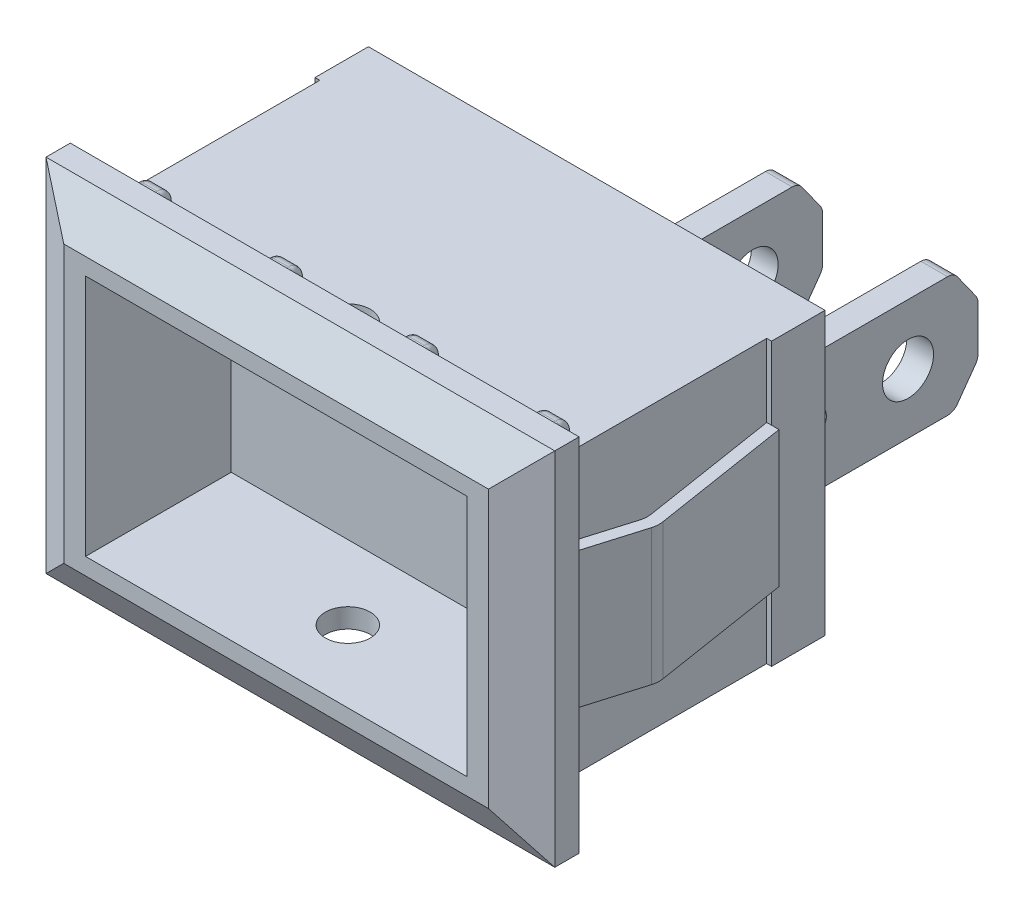
from build123d import *

# Parameters (mm, degrees)
IZIM1_W                           = 18.8
IZIM1_H                           = 11.6
Y_KSEKLIK_EKSTR_ZYON1_DEPTH       = 2.2
IZIM2_W                           = 18.4
IZIM2_H                           = 11.6
Y_KSEKLIK_EKSTR_ZYON2_DEPTH       = 9
IZIM3_W                           = 0.95
IZIM3_H                           = 3.7
Y_KSEKLIK_EKSTR_ZYON3_DEPTH       = 1
IZIM4_W                           = 0.95
IZIM4_H                           = 3.7
Y_KSEKLIK_EKSTR_ZYON4_DEPTH       = 1
IZIM5_W                           = 1.1
IZIM5_H                           = 4.95
Y_KSEKLIK_EKSTR_ZYON5_DEPTH       = 8.25
IZIM6_R                           = 1.05
KES_EKSTR_ZYON1_DEPTH             = 8.25
RADYUS1_R                         = 0.5
IZIM7_W                           = 20.95
IZIM7_H                           = 14.85
Y_KSEKLIK_EKSTR_ZYON6_DEPTH       = 2
KES_EKSTR_ZYON2_DEPTH             = 19
KES_EKSTR_ZYON3_DEPTH             = 23
IZIM10_W                          = 15.7
IZIM10_H                          = 10
KES_EKSTR_ZYON5_DEPTH             = 6
IZIM11_W                          = 1
IZIM11_H                          = 1.5
Y_KSEKLIK_EKSTR_ZYON7_DEPTH       = 0.7
RADYUS2_R                         = 0.5
RADYUS3_R                         = 0.2
IZIM13_W                          = 1
IZIM13_H                          = 1.5
Y_KSEKLIK_EKSTR_ZYON8_DEPTH       = 0.7
RADYUS4_R                         = 0.5
RADYUS5_R                         = 0.2
Y_KSEKLIK_EKSTR_ZYON9_DEPTH       = 2.8
Y_KSEKLIK_EKSTR_ZYON9_DEPTH_BACK  = 2.8
RADYUS6_R                         = 1
Y_KSEKLIK_EKSTR_ZYON10_DEPTH      = 2.8
Y_KSEKLIK_EKSTR_ZYON10_DEPTH_BACK = 2.8
RADYUS7_R                         = 1
IZIM17_R                          = 0.925
KES_EKSTR_ZYON7_DEPTH             = 20


with BuildPart() as part:
    # Çizim1 → Yükseklik-Ekstrüzyon1 (new body)
    with BuildSketch(Plane.XY):
        with Locations((9.4, 5.8)):
            Rectangle(IZIM1_W, IZIM1_H)
    extrude(amount=Y_KSEKLIK_EKSTR_ZYON1_DEPTH)

    # Çizim2 → Yükseklik-Ekstrüzyon2 (add)
    with BuildSketch(Plane.XY.offset(2.2)):
        with Locations((9.4, 5.8)):
            Rectangle(IZIM2_W, IZIM2_H)
    extrude(amount=Y_KSEKLIK_EKSTR_ZYON2_DEPTH)

    # Çizim3 → Yükseklik-Ekstrüzyon3 (add)
    with BuildSketch(Plane(origin=(0, 0, 0), x_dir=(-1, 0, 0), z_dir=(0, 0, -1))):
        with Locations((-1.475, 5.85)):
            Rectangle(IZIM3_W, IZIM3_H)
        with Locations((-3.425, 5.85)):
            Rectangle(IZIM3_W, IZIM3_H)
    extrude(amount=Y_KSEKLIK_EKSTR_ZYON3_DEPTH)

    # Çizim4 → Yükseklik-Ekstrüzyon4 (add)
    with BuildSketch(Plane(origin=(0, 0, 0), x_dir=(-1, 0, 0), z_dir=(0, 0, -1))):
        with Locations((-8.875, 5.85)):
            Rectangle(IZIM4_W, IZIM4_H)
        with Locations((-10.925, 5.85)):
            Rectangle(IZIM4_W, IZIM4_H)
        with Locations((-15.275, 5.85)):
            Rectangle(IZIM4_W, IZIM4_H)
        with Locations((-17.325, 5.85)):
            Rectangle(IZIM4_W, IZIM4_H)
    extrude(amount=Y_KSEKLIK_EKSTR_ZYON4_DEPTH)

    # Çizim5 → Yükseklik-Ekstrüzyon5 (add)
    with BuildSketch(Plane(origin=(0, 0, 0), x_dir=(-1, 0, 0), z_dir=(0, 0, -1))):
        with Locations((-16.3, 5.85)):
            Rectangle(IZIM5_W, IZIM5_H)
        with Locations((-9.9, 5.85)):
            Rectangle(IZIM5_W, IZIM5_H)
    extrude(amount=Y_KSEKLIK_EKSTR_ZYON5_DEPTH)

    # Çizim6 → Kes-Ekstrüzyon1 (cut)
    with BuildSketch(Plane(origin=(16.85, 0, 0), x_dir=(0, 0, -1), z_dir=(1, 0, 0))):
        with Locations((5.369684308, 5.85)):
            Circle(IZIM6_R)
        Polygon((7.255067315, 8.325), (8.25, 6.93078897), (8.25, 8.325), align=None)
        with BuildLine():
            Line((1, 6.321269279), (1, 5.378730721))
            ThreePointArc((1, 5.378730721), (2.005481155, 5.85), (1, 6.321269279))
        make_face()
        Polygon((7.255067315, 3.375), (8.25, 4.76921103), (8.25, 3.375), align=None)
    extrude(amount=-KES_EKSTR_ZYON1_DEPTH, mode=Mode.SUBTRACT)

    # Radyus1
    radyus1_edges = [part.edges().sort_by_distance(p)[0] for p in [
        (9.9, 4.76921103, -8.25),
        (9.9, 6.93078897, -8.25),
        (16.3, 8.325, -7.255067315),
        (9.9, 8.325, -7.255067315),
        (16.3, 6.93078897, -8.25),
        (16.3, 4.76921103, -8.25),
        (16.3, 3.375, -7.255067315),
        (9.9, 3.375, -7.255067315),
    ]]
    fillet(radyus1_edges, radius=RADYUS1_R)

    # Çizim7 → Yükseklik-Ekstrüzyon6 (add)
    with BuildSketch(Plane.XY.offset(11.2)):
        with Locations((9.4, 5.8)):
            Rectangle(IZIM7_W, IZIM7_H)
    extrude(amount=Y_KSEKLIK_EKSTR_ZYON6_DEPTH)

    # Çizim8 → Kes-Ekstrüzyon2 (cut)
    with BuildSketch(Plane(origin=(0, 13.225, 0), x_dir=(1, 0, 0), z_dir=(0, 1, 0))):
        Polygon((19.875, -12.2), (18.142949192, -13.2), (19.875, -13.2), align=None)
        Polygon((-1.075, -13.2), (0.657050808, -13.2), (-1.075, -12.2), align=None)
    extrude(amount=-KES_EKSTR_ZYON2_DEPTH, mode=Mode.SUBTRACT)

    # Çizim9 → Kes-Ekstrüzyon3 (cut)
    with BuildSketch(Plane.ZY.offset(1.075)):
        Polygon((13.2, 13.225), (12.2, 13.225), (13.2, 11.495), align=None)
        Polygon((13.2, 0.105), (13.2, -1.625), (12.2, -1.625), align=None)
    extrude(amount=-KES_EKSTR_ZYON3_DEPTH, mode=Mode.SUBTRACT)

    # Çizim10 → Kes-Ekstrüzyon5 (cut)
    with BuildSketch(Plane.XY.offset(13.2)):
        with Locations((9.402050808, 5.8)):
            Rectangle(IZIM10_W, IZIM10_H)
    extrude(amount=-KES_EKSTR_ZYON5_DEPTH, mode=Mode.SUBTRACT)

    # Çizim11 → Yükseklik-Ekstrüzyon7 (add)
    with BuildSketch(Plane(origin=(0, 11.6, 0), x_dir=(1, 0, 0), z_dir=(0, 1, 0))):
        with Locations((1.2, -10.45)):
            Rectangle(IZIM11_W, IZIM11_H)
        with Locations((6.6, -10.45)):
            Rectangle(IZIM11_W, IZIM11_H)
        with Locations((12.2, -10.45)):
            Rectangle(IZIM11_W, IZIM11_H)
        with Locations((17.6, -10.45)):
            Rectangle(IZIM11_W, IZIM11_H)
    extrude(amount=Y_KSEKLIK_EKSTR_ZYON7_DEPTH)

    # Radyus2
    radyus2_edges = [part.edges().sort_by_distance(p)[0] for p in [
        (1.2, 12.3, 9.7),
        (6.6, 12.3, 9.7),
        (12.2, 12.3, 9.7),
        (17.6, 12.3, 9.7),
    ]]
    fillet(radyus2_edges, radius=RADYUS2_R)

    # Radyus3
    radyus3_edges = [part.edges().sort_by_distance(p)[0] for p in [
        (1.7, 12.3, 10.7),
        (7.1, 12.3, 10.7),
        (12.7, 12.3, 10.7),
        (18.1, 12.3, 10.7),
        (17.1, 12.3, 10.7),
        (17.1, 11.7, 9.7),
        (17.1, 12.153553391, 9.846446609),
        (18.1, 11.7, 9.7),
        (18.1, 12.153553391, 9.846446609),
        (11.7, 12.3, 10.7),
        (11.7, 11.7, 9.7),
        (11.7, 12.153553391, 9.846446609),
        (12.7, 11.7, 9.7),
        (12.7, 12.153553391, 9.846446609),
        (6.1, 12.3, 10.7),
        (6.1, 11.7, 9.7),
        (6.1, 12.153553391, 9.846446609),
        (7.1, 11.7, 9.7),
        (7.1, 12.153553391, 9.846446609),
        (0.7, 12.3, 10.7),
        (0.7, 11.7, 9.7),
        (0.7, 12.153553391, 9.846446609),
        (1.7, 11.7, 9.7),
        (1.7, 12.153553391, 9.846446609),
    ]]
    fillet(radyus3_edges, radius=RADYUS3_R)

    # Çizim13 → Yükseklik-Ekstrüzyon8 (add)
    with BuildSketch(Plane.XZ):
        with Locations((1.2, 10.45)):
            Rectangle(IZIM13_W, IZIM13_H)
        with Locations((6.6, 10.45)):
            Rectangle(IZIM13_W, IZIM13_H)
        with Locations((12.2, 10.45)):
            Rectangle(IZIM13_W, IZIM13_H)
        with Locations((17.6, 10.45)):
            Rectangle(IZIM13_W, IZIM13_H)
    extrude(amount=Y_KSEKLIK_EKSTR_ZYON8_DEPTH)

    # Radyus4
    radyus4_edges = [part.edges().sort_by_distance(p)[0] for p in [
        (1.2, -0.7, 9.7),
        (6.6, -0.7, 9.7),
        (12.2, -0.7, 9.7),
        (17.6, -0.7, 9.7),
    ]]
    fillet(radyus4_edges, radius=RADYUS4_R)

    # Radyus5
    radyus5_edges = [part.edges().sort_by_distance(p)[0] for p in [
        (0.7, -0.7, 10.7),
        (6.1, -0.7, 10.7),
        (11.7, -0.7, 10.7),
        (17.1, -0.7, 10.7),
        (18.1, -0.7, 10.7),
        (18.1, -0.1, 9.7),
        (18.1, -0.553553391, 9.846446609),
        (17.1, -0.1, 9.7),
        (17.1, -0.553553391, 9.846446609),
        (12.7, -0.7, 10.7),
        (12.7, -0.1, 9.7),
        (12.7, -0.553553391, 9.846446609),
        (11.7, -0.1, 9.7),
        (11.7, -0.553553391, 9.846446609),
        (7.1, -0.7, 10.7),
        (7.1, -0.1, 9.7),
        (7.1, -0.553553391, 9.846446609),
        (6.1, -0.1, 9.7),
        (6.1, -0.553553391, 9.846446609),
        (1.7, -0.7, 10.7),
        (1.7, -0.1, 9.7),
        (1.7, -0.553553391, 9.846446609),
        (0.7, -0.1, 9.7),
        (0.7, -0.553553391, 9.846446609),
    ]]
    fillet(radyus5_edges, radius=RADYUS5_R)

    # Çizim14 → Yükseklik-Ekstrüzyon9 (add, two sides)
    with BuildSketch(Plane(origin=(0, 5.8, 0), x_dir=(1, 0, 0), z_dir=(0, 1, 0))) as y_kseklik_ekstr_zyon9_sk:
        Polygon((19.106211635, -2.2), (20.040349582, -8.107903313), (19.121604356, -11.2), (18.6, -11.2), (19.528791698, -8.074091259), (18.6, -2.2), align=None)
    extrude(amount=Y_KSEKLIK_EKSTR_ZYON9_DEPTH)
    extrude(y_kseklik_ekstr_zyon9_sk.sketch, amount=-Y_KSEKLIK_EKSTR_ZYON9_DEPTH_BACK)

    # Radyus6
    radyus6_edges = [part.edges().sort_by_distance(p)[0] for p in [
        (20.040349582, 5.8, 8.107903313),
        (19.528791698, 5.8, 8.074091259),
    ]]
    fillet(radyus6_edges, radius=RADYUS6_R)

    # Çizim15 → Yükseklik-Ekstrüzyon10 (add, two sides)
    with BuildSketch(Plane(origin=(0, 5.8, 0), x_dir=(1, 0, 0), z_dir=(0, 1, 0))) as y_kseklik_ekstr_zyon10_sk:
        Polygon((0.2, -11.2), (-0.73, -8.07), (0.735343687, -2.2), (0.22, -2.2), (-1.248201965, -8.081449937), (-0.321604023, -11.2), align=None)
    extrude(amount=Y_KSEKLIK_EKSTR_ZYON10_DEPTH)
    extrude(y_kseklik_ekstr_zyon10_sk.sketch, amount=-Y_KSEKLIK_EKSTR_ZYON10_DEPTH_BACK)

    # Radyus7
    radyus7_edges = [part.edges().sort_by_distance(p)[0] for p in [
        (-1.248201965, 5.8, 8.081449937),
        (-0.73, 5.8, 8.07),
    ]]
    fillet(radyus7_edges, radius=RADYUS7_R)

    # Çizim17 → Kes-Ekstrüzyon7 (cut)
    with BuildSketch(Plane(origin=(0, 11.6, 0), x_dir=(1, 0, 0), z_dir=(0, 1, 0))):
        with Locations((9.4, -10.247235837)):
            Circle(IZIM17_R)
    extrude(amount=-KES_EKSTR_ZYON7_DEPTH, mode=Mode.SUBTRACT)


solid = part.part
